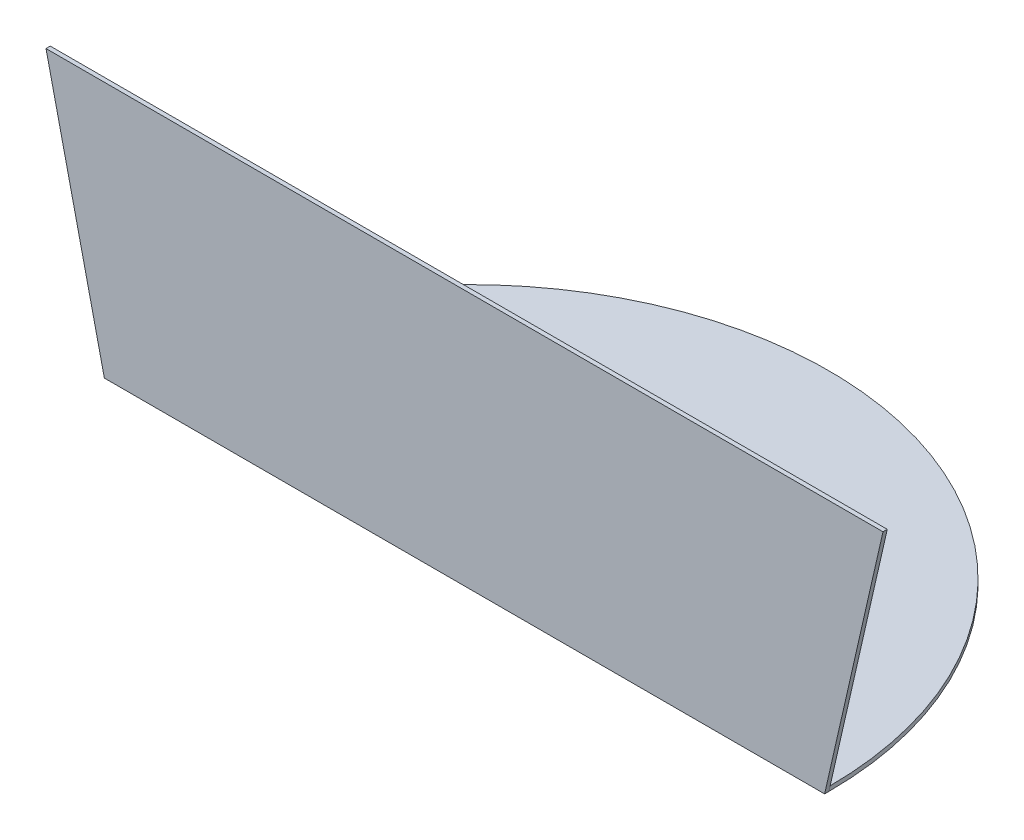
from build123d import *

# Parameters (mm, degrees)
AUFSATZ_LINEAR_AUSTRAGEN2_DEPTH = 1.5
AUFSATZ_LINEAR_AUSTRAGEN3_DEPTH = 1.5


with BuildPart() as part:
    # Skizze1 → Aufsatz-Linear austragen2 (new body)
    with BuildSketch(Plane(origin=(0, 0, 0), x_dir=(1, 0, 0), z_dir=(0, 1, 0))):
        with BuildLine():
            Line((-126.5, 0), (126.5, 0))
            ThreePointArc((126.5, 0), (0, 126.5), (-126.5, 0))
        make_face()
    extrude(amount=AUFSATZ_LINEAR_AUSTRAGEN2_DEPTH)

    # Skizze2 → Aufsatz-Linear austragen3 (add)
    with BuildSketch(Plane.XY):
        Polygon((126.5, 0), (147, 90), (-147, 90), (-126.5, 0), align=None)
    extrude(amount=AUFSATZ_LINEAR_AUSTRAGEN3_DEPTH)


solid = part.part
